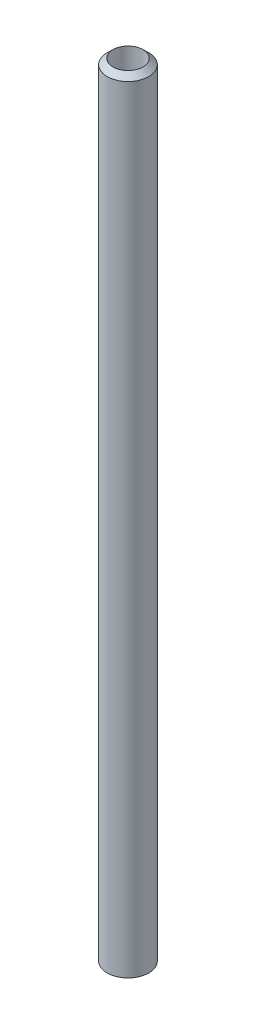
from build123d import *

# Parameters (mm, degrees)
SKETCH1_R           = 4.826
BOSS_EXTRUDE1_DEPTH = 180.34
SKETCH2_R           = 3.4925
BOSS_EXTRUDE2_DEPTH = 1.27
SKETCH3_R           = 3.49123
CUT_EXTRUDE2_DEPTH  = 203.2


with BuildPart() as part:
    # Sketch1 → Boss-Extrude1 (new body)
    with BuildSketch(Plane(origin=(0, 0, 0), x_dir=(1, 0, 0), z_dir=(0, 1, 0))):
        with Locations(Location((0, 0, 0), (0, 0, 270))):
            Circle(SKETCH1_R)
    extrude(amount=BOSS_EXTRUDE1_DEPTH)

    # Sketch2 → Boss-Extrude2 (add)
    with BuildSketch(Plane(origin=(0, 180.34, 0), x_dir=(1, 0, 0), z_dir=(0, 1, 0))):
        with Locations(Location((0, 0, 0), (0, 0, 270))):
            Circle(SKETCH2_R)
    extrude(amount=BOSS_EXTRUDE2_DEPTH)

    # loft from a face of the part (loft3)
    loft([part.faces().sort_by_distance((0, 181.61, 0))[0], Face(Wire([part.edges().sort_by_distance((3.518002596, 180.34, -3.303624333))[0]]))])

    # Sketch3 → Cut-Extrude2 (cut)
    with BuildSketch(Plane(origin=(0, 181.61, 0), x_dir=(1, 0, 0), z_dir=(0, 1, 0))):
        with Locations(Location((0, 0, 0), (0, 0, 270))):
            Circle(SKETCH3_R)
    extrude(amount=-CUT_EXTRUDE2_DEPTH, mode=Mode.SUBTRACT)


solid = part.part
